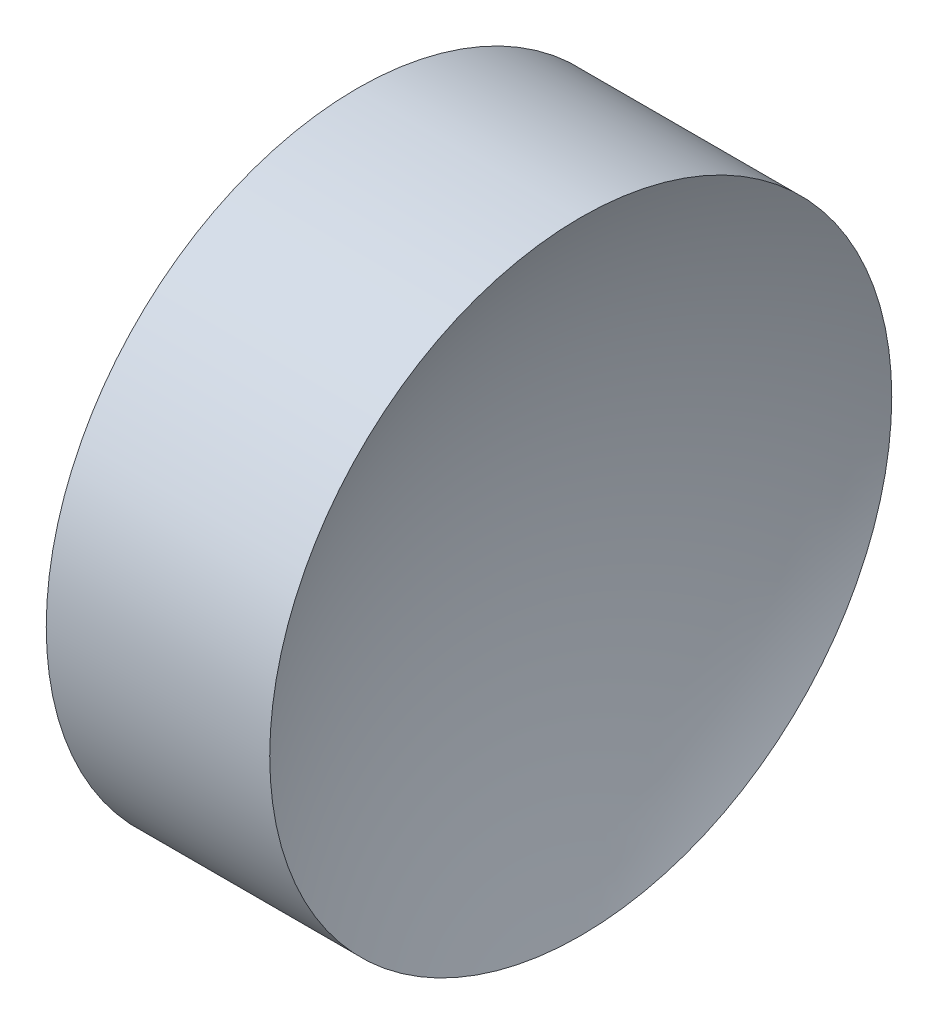
from build123d import *


with BuildPart() as part:
    # 草图1 → 旋转1 (revolve)
    with BuildSketch(Plane.XY, mode=Mode.PRIVATE) as revolve_1_sk:
        with BuildLine():
            Line((22.200875489, 13.031126091), (22.200875489, 16.181126091))
            Line((22.200875489, 16.181126091), (24.46435373, 16.181126091))
            ThreePointArc((24.46435373, 16.181126091), (23.894472506, 14.651727163), (23.700880523, 13.031126091))
            Line((23.700880523, 13.031126091), (22.200875489, 13.031126091))
        make_face()
    revolve(revolve_1_sk.sketch.rotate(Axis((21.156471922, 13.031126091, 0), (1, 0, 0)), 180), axis=Axis((21.156471922, 13.031126091, 0), (1, 0, 0)))  # turned: the seam where the file's is


solid = part.part
